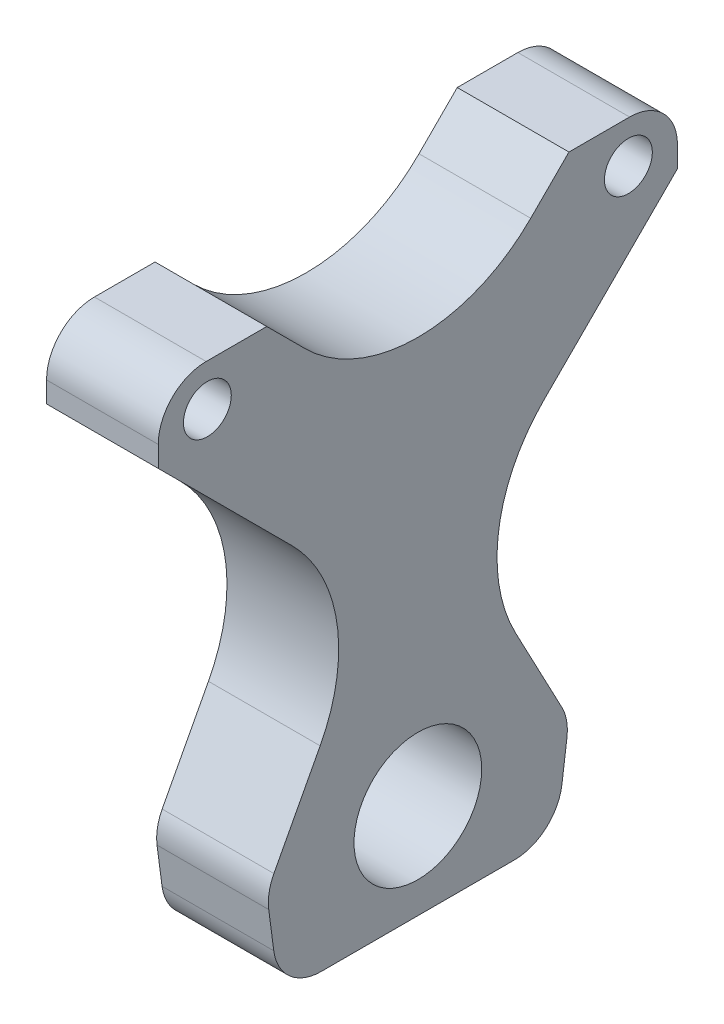
from build123d import *

# Parameters (mm, degrees)
SKETCH1_R           = 1.5
SKETCH1_R_2         = 4
BOSS_EXTRUDE3_DEPTH = 7


with BuildPart() as part:
    # Sketch1 → Boss-Extrude3 (new body)
    with BuildSketch(Plane(origin=(0, 0, 0), x_dir=(0, 0, -1), z_dir=(1, 0, 0))):
        with BuildLine():
            Line((-16.265163927, 11.0728645), (-7.889471404, 2.697171977))
            ThreePointArc((-7.889471404, 2.697171977), (-5.072000749, -2.885001281), (-6.120829891, -9.049314431))
            Line((-6.120829891, -9.049314431), (-9.01992916, -14.530576551))
            ThreePointArc((-9.01992916, -14.530576551), (-9.320687391, -15.40241611), (-9.342398614, -16.32441847))
            Line((-9.342398614, -16.32441847), (-9.027333312, -18.719831292))
            ThreePointArc((-9.027333312, -18.719831292), (-8.031125849, -20.584013921), (-6.052951061, -21.328614951))
            Line((-6.052951061, -21.328614951), (6.052951061, -21.328614951))
            ThreePointArc((6.052951061, -21.328614951), (8.031125849, -20.584013921), (9.027333312, -18.719831292))
            Line((9.027333312, -18.719831292), (9.342398614, -16.32441847))
            ThreePointArc((9.342398614, -16.32441847), (9.320687391, -15.40241611), (9.01992916, -14.530576551))
            Line((9.01992916, -14.530576551), (6.120829891, -9.049314431))
            ThreePointArc((6.120829891, -9.049314431), (5.072000749, -2.885001281), (7.889471404, 2.697171977))
            Line((7.889471404, 2.697171977), (16.265163927, 11.0728645))
            Line((16.265163927, 11.0728645), (16.265163927, 12.376090748))
            ThreePointArc((16.265163927, 12.376090748), (15.386484271, 14.497411092), (13.265163927, 15.376090748))
            Line((13.265163927, 15.376090748), (9.467130834, 15.376090748))
            Line((9.467130834, 15.376090748), (7.071067812, 12.980027727))
            ThreePointArc((7.071067812, 12.980027727), (0, 10.051095538), (-7.071067812, 12.980027727))
            Line((-7.071067812, 12.980027727), (-9.467130834, 15.376090748))
            Line((-9.467130834, 15.376090748), (-13.265163927, 15.376090748))
            ThreePointArc((-13.265163927, 15.376090748), (-15.386484271, 14.497411092), (-16.265163927, 12.376090748))
            Line((-16.265163927, 12.376090748), (-16.265163927, 11.0728645))
        make_face()
        with Locations((-13.189368773, 12.756003002)):
            Circle(SKETCH1_R, mode=Mode.SUBTRACT)
        with Locations((13.189368773, 12.756003002)):
            Circle(SKETCH1_R, mode=Mode.SUBTRACT)
        with Locations((0, -15.376090748)):
            Circle(SKETCH1_R_2, mode=Mode.SUBTRACT)
    extrude(amount=BOSS_EXTRUDE3_DEPTH)


solid = part.part
